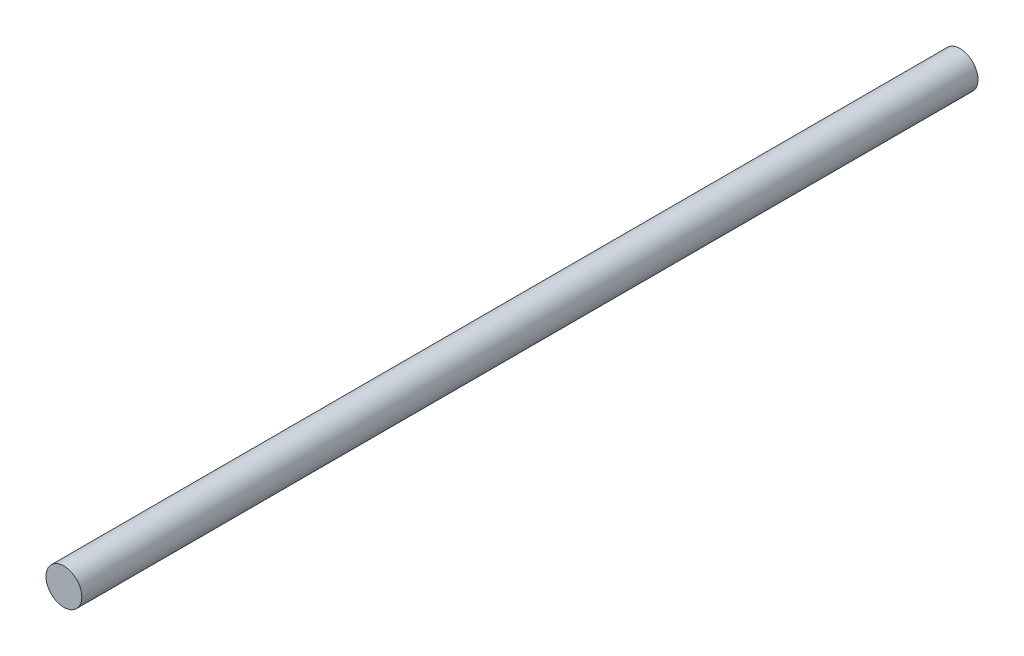
from build123d import *

# Parameters (mm, degrees)
SKIZZE1_R                       = 6
AUFSATZ_LINEAR_AUSTRAGEN1_DEPTH = 300


with BuildPart() as part:
    # Skizze1 → Aufsatz-Linear austragen1 (new body)
    with BuildSketch(Plane.XY):
        Circle(SKIZZE1_R)
    extrude(amount=AUFSATZ_LINEAR_AUSTRAGEN1_DEPTH)


solid = part.part
